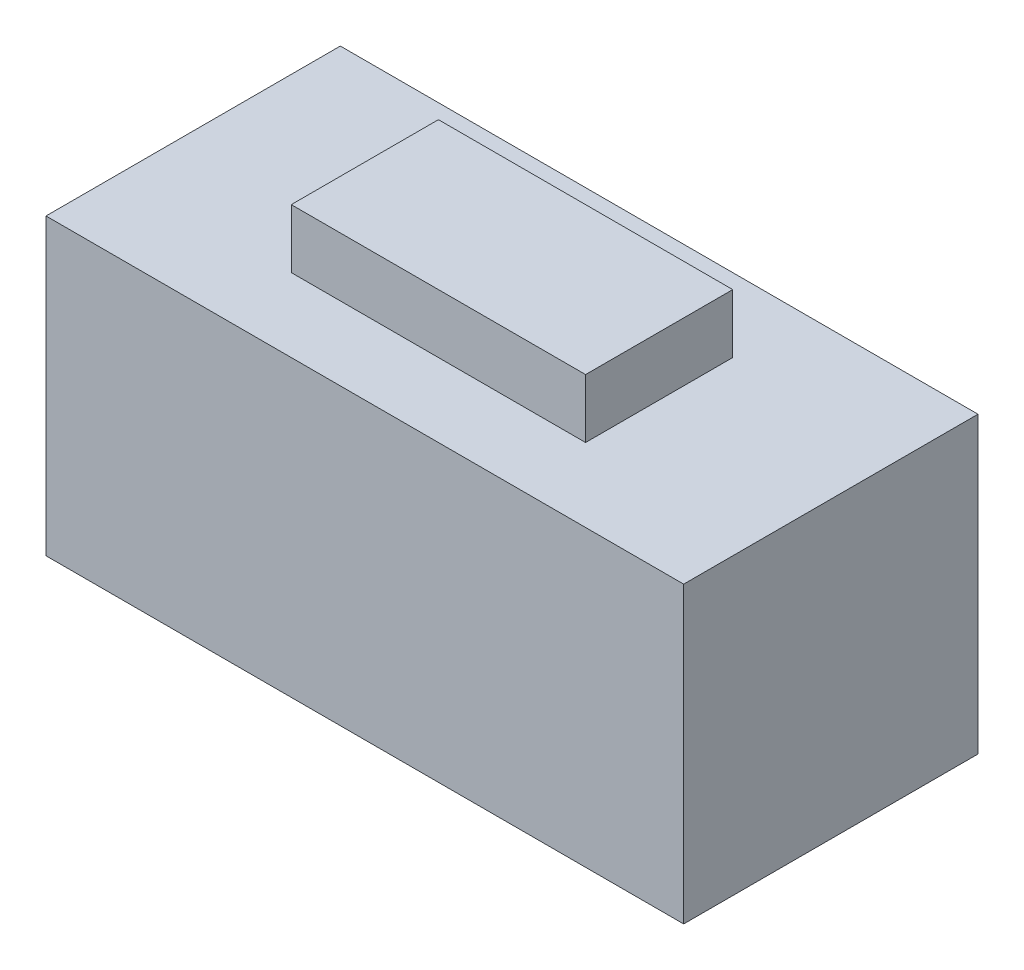
from build123d import *

# Parameters (mm, degrees)
SKETCH1_W           = 6.5
SKETCH1_H           = 3
BOSS_EXTRUDE1_DEPTH = 3
SKETCH2_W           = 3
SKETCH2_H           = 1.5
BOSS_EXTRUDE2_DEPTH = 0.6


with BuildPart() as part:
    # Sketch1 → Boss-Extrude1 (new body)
    with BuildSketch(Plane(origin=(0, 0, 0), x_dir=(1, 0, 0), z_dir=(0, 1, 0))):
        Rectangle(SKETCH1_W, SKETCH1_H)
    extrude(amount=BOSS_EXTRUDE1_DEPTH)

    # Sketch2 → Boss-Extrude2 (add)
    with BuildSketch(Plane(origin=(0, 3, 0), x_dir=(1, 0, 0), z_dir=(0, 1, 0))):
        Rectangle(SKETCH2_W, SKETCH2_H)
    extrude(amount=BOSS_EXTRUDE2_DEPTH)


solid = part.part
